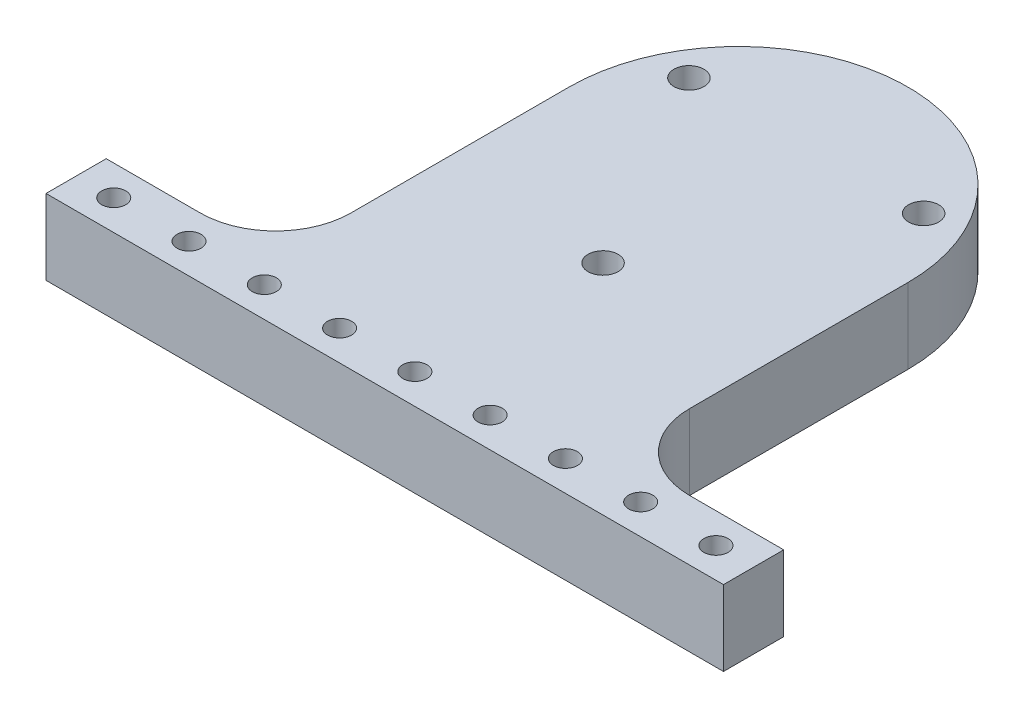
from build123d import *

# Parameters (mm, degrees)
SKETCH1_W           = 90
SKETCH1_H           = 8
BOSS_EXTRUDE1_DEPTH = 10
BOSS_EXTRUDE2_DEPTH = 10
SKETCH4_R           = 2
CUT_EXTRUDE1_DEPTH  = 11
FILLET1_R           = 10
SKETCH5_R           = 1.6
CUT_EXTRUDE2_DEPTH  = 11
LPATTERN1_COUNT     = 10
LPATTERN1_PITCH     = 10


with BuildPart() as part:
    # Sketch1 → Boss-Extrude1 (new body)
    with BuildSketch(Plane(origin=(0, 0, 0), x_dir=(1, 0, 0), z_dir=(0, 1, 0))):
        Rectangle(SKETCH1_W, SKETCH1_H)
    extrude(amount=BOSS_EXTRUDE1_DEPTH)

    # Sketch3 → Boss-Extrude2 (add)
    with BuildSketch(Plane(origin=(0, 0, 0), x_dir=(1, 0, 0), z_dir=(0, 1, 0))):
        with BuildLine():
            Line((-22.5, 43.000049343), (-22.5, 4))
            Line((-22.5, 4), (22.5, 4))
            Line((22.5, 4), (22.5, 43.000049343))
            ThreePointArc((22.5, 43.000049343), (0, 65.500049343), (-22.5, 43.000049343))
        make_face()
    extrude(amount=BOSS_EXTRUDE2_DEPTH)

    # Sketch4 → Cut-Extrude1 (cut, through all)
    with BuildSketch(Plane(origin=(0, 10, 0), x_dir=(1, 0, 0), z_dir=(0, 1, 0))):
        with Locations((-15.5885, 52.000074014)):
            Circle(SKETCH4_R)
        with Locations((15.5885, 52.000074014)):
            Circle(SKETCH4_R)
        with Locations((0, 25)):
            Circle(SKETCH4_R)
    extrude(amount=-CUT_EXTRUDE1_DEPTH, mode=Mode.SUBTRACT)

    # Fillet1
    fillet1_edges = [part.edges().sort_by_distance(p)[0] for p in [
        (22.5, 5, -4),
        (-22.5, 5, -4),
    ]]
    fillet(fillet1_edges, radius=FILLET1_R)

    # Sketch5 → Cut-Extrude2 (cut, through all)
    with BuildSketch(Plane(origin=(0, 10, 0), x_dir=(1, 0, 0), z_dir=(0, 1, 0))):
        with Locations((-40, 0)):
            Circle(SKETCH5_R)
    cut_extrude2 = extrude(amount=-CUT_EXTRUDE2_DEPTH, mode=Mode.SUBTRACT)

    # LPattern1: Cut-Extrude2 ×10
    with Locations(*[(i * LPATTERN1_PITCH, 0, 0) for i in range(1, LPATTERN1_COUNT)]):
        add(cut_extrude2, mode=Mode.SUBTRACT)


solid = part.part
